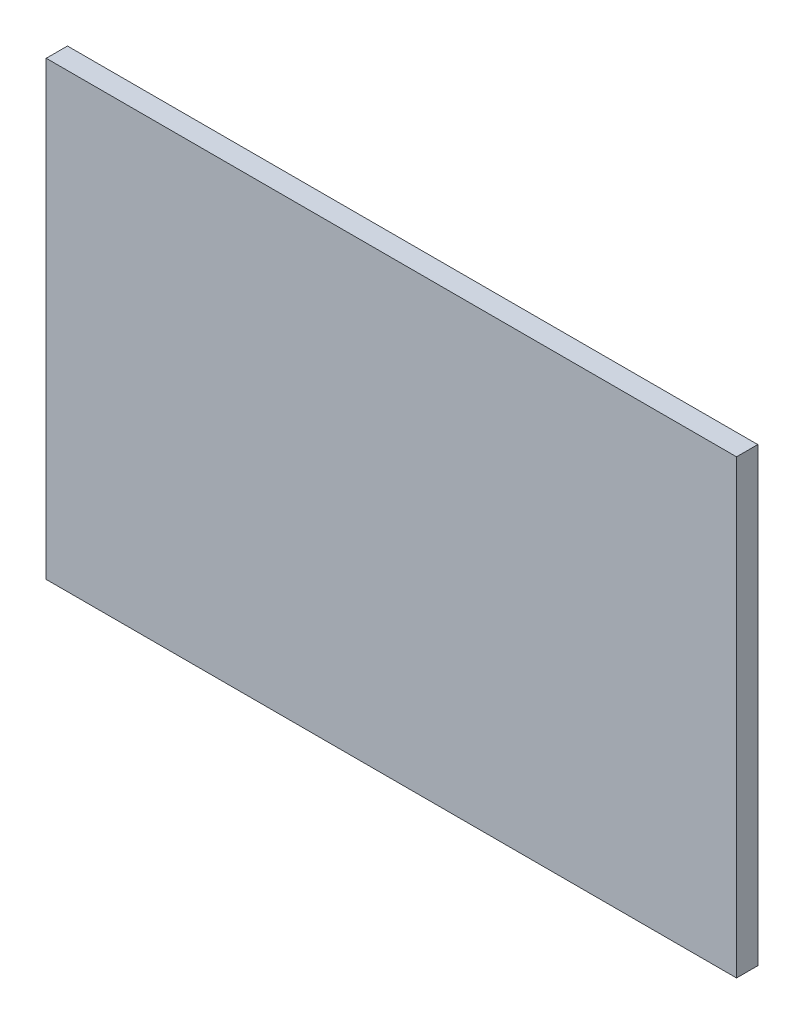
from build123d import *

# Parameters (mm, degrees)
SKETCH1_W           = 26
SKETCH1_H           = 17
BOSS_EXTRUDE1_DEPTH = 0.8


with BuildPart() as part:
    # Sketch1 → Boss-Extrude1 (new body)
    with BuildSketch(Plane.XY):
        with Locations((13, -8.5)):
            Rectangle(SKETCH1_W, SKETCH1_H)
    extrude(amount=BOSS_EXTRUDE1_DEPTH)


solid = part.part
